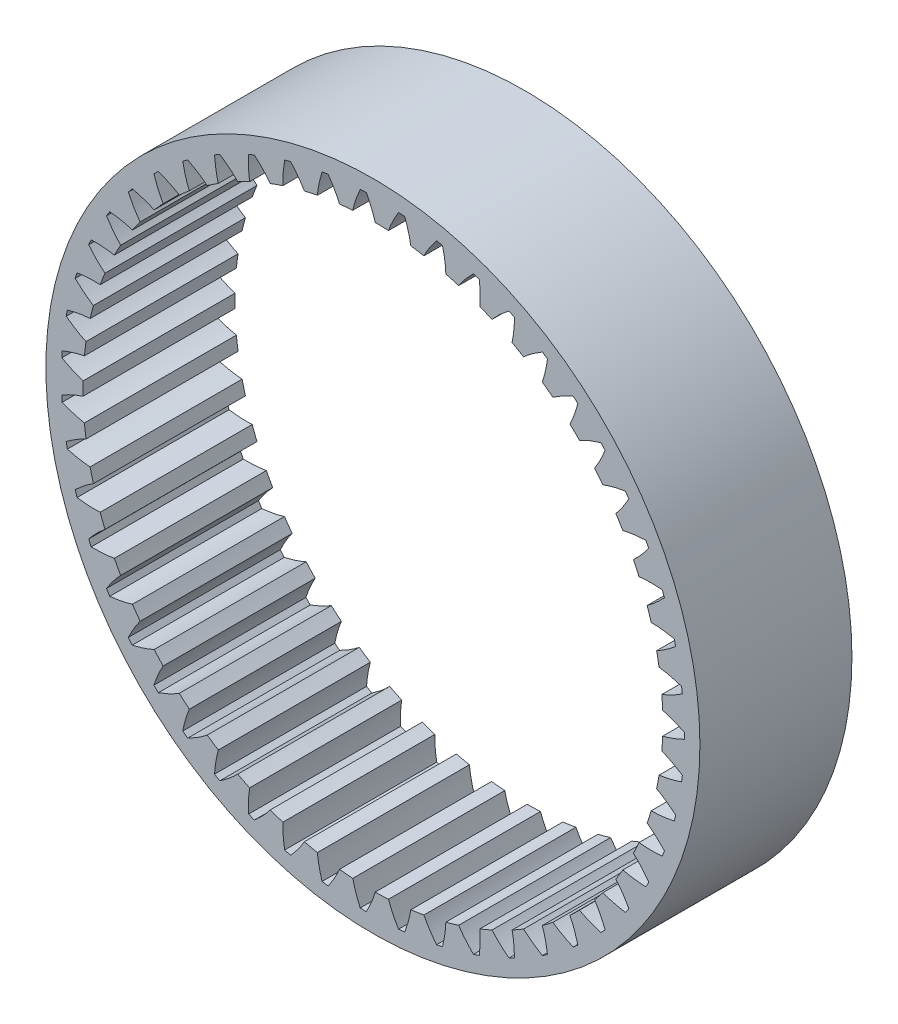
from build123d import *

# Parameters (mm, degrees)
SKETCH3_R           = 14.413170677
SKETCH3_R_2         = 12.779268244
BOSS_EXTRUDE2_DEPTH = 6.7
CUT_EXTRUDE2_DEPTH  = 7.7
CIRPATTERN1_COUNT   = 51


with BuildPart() as part:
    # Sketch3 → Boss-Extrude2 (new body)
    with BuildSketch(Plane.XY):
        Circle(SKETCH3_R)
        Circle(SKETCH3_R_2, mode=Mode.SUBTRACT)
    extrude(amount=BOSS_EXTRUDE2_DEPTH)

    # Sketch1 → Cut-Extrude2 (cut, through all)
    with BuildSketch(Plane.XY):
        with BuildLine():
            Line((13.72615817, 0.135733799), (13.72615817, -0.135733799))
            add(Edge.make_bspline(
                [(12.769715215, -0.494035854), (12.776574111, -0.492330686), (12.790035774, -0.488931181), (12.821574661, -0.480855079), (12.847555146, -0.473780112), (12.883037295, -0.464047997), (12.912691253, -0.45547992), (12.945746782, -0.445784781), (12.976614207, -0.436365358), (13.008699632, -0.426370641), (13.039899017, -0.416347103), (13.071555606, -0.405937604), (13.102741837, -0.395425085), (13.134199694, -0.384554527), (13.172321724, -0.371117615), (13.218755008, -0.354199935), (13.271565793, -0.334431224), (13.33373375, -0.310033015), (13.393326926, -0.286021333), (13.457142781, -0.259042765), (13.513348434, -0.234899297), (13.581176706, -0.204218207), (13.628997859, -0.182472569), (13.689081493, -0.153716373), (13.713457548, -0.14193902), (13.72615817, -0.135733799)],
                knots=[0.060378475, 0.060378475, 0.060378475, 0.060378475, 0.060378475, 0.088008109, 0.11563793, 0.14326768, 0.170897428, 0.198527297, 0.22615695, 0.253786788, 0.281416525, 0.309046301, 0.336676096, 0.364305819, 0.391935638, 0.419565403, 0.472503509, 0.527763064, 0.583022611, 0.638282123, 0.693541711, 0.748801217, 0.804060785, 0.859320271, 0.914579864, 0.914579864, 0.914579864, 0.914579864, 0.914579864], degree=4))
            Line((12.769715215, -0.494035854), (12.769715215, 0.494035854))
            add(Edge.make_bspline(
                [(12.769715215, 0.494035854), (12.776574111, 0.492330686), (12.790035774, 0.488931181), (12.821574661, 0.480855079), (12.847555146, 0.473780112), (12.883037295, 0.464047997), (12.912691253, 0.45547992), (12.945746782, 0.445784781), (12.976614207, 0.436365358), (13.008699632, 0.426370641), (13.039899017, 0.416347103), (13.071555606, 0.405937604), (13.102741837, 0.395425085), (13.134199694, 0.384554527), (13.172321724, 0.371117615), (13.218755008, 0.354199935), (13.271565793, 0.334431224), (13.33373375, 0.310033015), (13.393326926, 0.286021333), (13.457142781, 0.259042765), (13.513348434, 0.234899297), (13.581176706, 0.204218207), (13.628997859, 0.182472569), (13.689081493, 0.153716373), (13.713457548, 0.14193902), (13.72615817, 0.135733799)],
                knots=[0.060378475, 0.060378475, 0.060378475, 0.060378475, 0.060378475, 0.088008109, 0.11563793, 0.14326768, 0.170897428, 0.198527297, 0.22615695, 0.253786788, 0.281416525, 0.309046301, 0.336676096, 0.364305819, 0.391935638, 0.419565403, 0.472503509, 0.527763064, 0.583022611, 0.638282123, 0.693541711, 0.748801217, 0.804060785, 0.859320271, 0.914579864, 0.914579864, 0.914579864, 0.914579864, 0.914579864], degree=4))
        make_face()
    cut_extrude2 = extrude(amount=CUT_EXTRUDE2_DEPTH, mode=Mode.SUBTRACT)

    # CirPattern1: Cut-Extrude2 ×51 about axis
    cirpattern1_axis = Axis((0, 0, 6.928898804), (0, 0, -1))
    for i in range(1, CIRPATTERN1_COUNT):
        add(cut_extrude2.rotate(cirpattern1_axis, i * 360 / CIRPATTERN1_COUNT), mode=Mode.SUBTRACT)


solid = part.part
